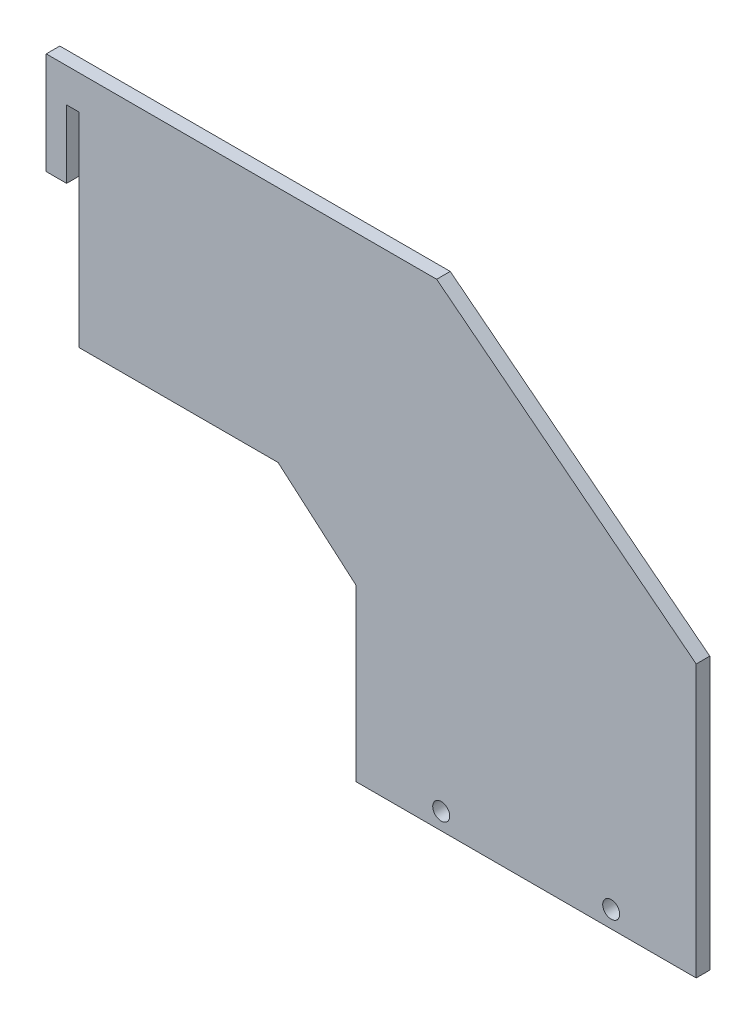
from build123d import *

# Parameters (mm, degrees)
EXTRUDE_1_DEPTH     = 4
SKETCH_2_R          = 2.5
CUT_EXTRUDE_1_DEPTH = 5


with BuildPart() as part:
    # Эскиз1 → Бобышка-Вытянуть1 (new body)
    with BuildSketch(Plane.XY):
        Polygon((87.193826731, -36.850553491), (87.193826731, -86.850553491), (187.193824318, -86.828585686), (187.193824318, -6.828585686), (110.85, 53.001797886), (6, 53.001797886), (-4, 53.001797886), (-4, 23.001797886), (2, 23.001797886), (2, 43.001797886), (5.711449025, 43.001797886), (5.711449025, -16.998202114), (64.208325653, -16.998202114), align=None)
    extrude(amount=EXTRUDE_1_DEPTH)

    # Эскиз2 → Вырез-Вытянуть1 (cut, through all)
    with BuildSketch(Plane.XY.offset(4)):
        with Locations((112.19490079, -81.850553491)):
            Circle(SKETCH_2_R)
        with Locations((162.19490079, -81.850553491)):
            Circle(SKETCH_2_R)
    extrude(amount=-CUT_EXTRUDE_1_DEPTH, mode=Mode.SUBTRACT)


solid = part.part
